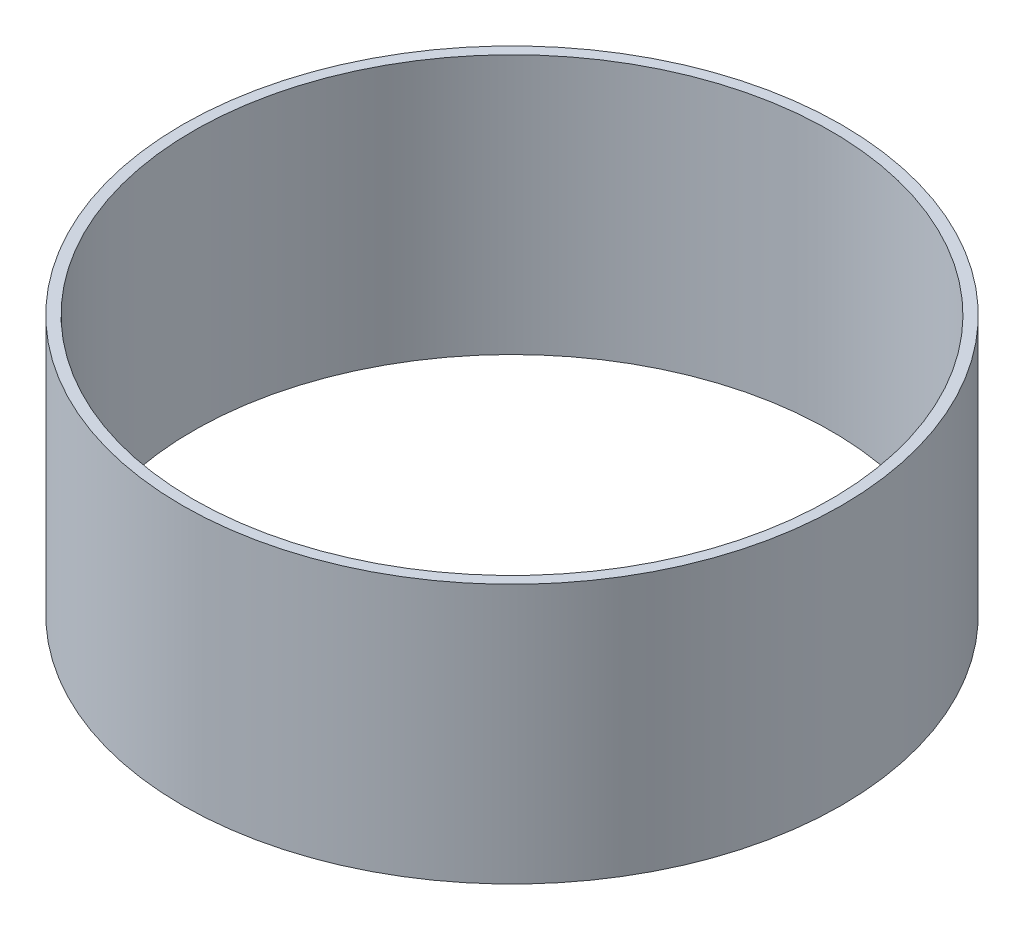
from build123d import *

# Parameters (mm, degrees)
ESQUISSE1_R        = 152.4
ESQUISSE1_R_2      = 147.4
BOSS_EXTRU_1_DEPTH = 120


with BuildPart() as part:
    # Esquisse1 → Boss.-Extru.1 (new body)
    with BuildSketch(Plane(origin=(0, 0, 0), x_dir=(1, 0, 0), z_dir=(0, 1, 0))):
        Circle(ESQUISSE1_R)
        Circle(ESQUISSE1_R_2, mode=Mode.SUBTRACT)
    extrude(amount=BOSS_EXTRU_1_DEPTH)


solid = part.part
